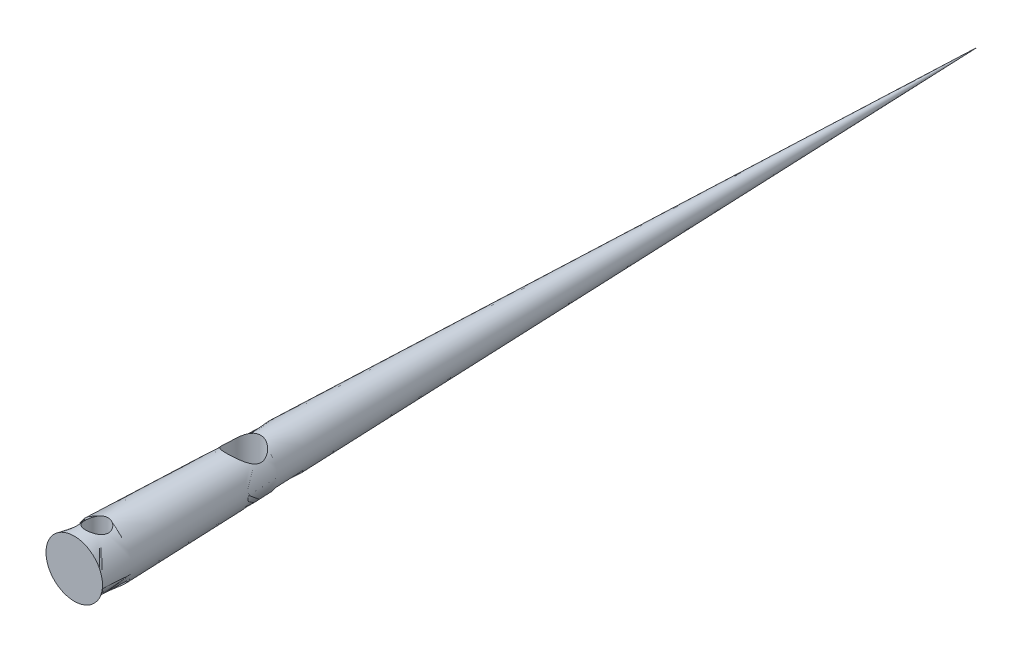
from build123d import *

# Parameters (mm, degrees)
SKETCH4_R               = 1.5
CUT_EXTRUDE3_DEPTH      = 3.5
CUT_EXTRUDE3_DEPTH_BACK = 3.5
SKETCH7_R               = 1
CUT_EXTRUDE4_DEPTH      = 3.5000001
CUT_EXTRUDE4_DEPTH_BACK = 3.5000001


with BuildPart() as part:
    # Sketch2 → Revolve2 (revolve)
    with BuildSketch(Plane(origin=(0, 0, 0), x_dir=(1, 0, 0), z_dir=(0, 1, 0))):
        Polygon((0, 0), (2.5, 0), (0, 80), align=None)
    revolve(axis=Axis((0, 0, -80), (0, 0, 1)))

    # Sketch4 → Cut-Extrude3 (cut, two sides)
    with BuildSketch(Plane(origin=(0, 0, 0), x_dir=(1, 0, 0), z_dir=(0, 1, 0))) as cut_extrude3_sk:
        with Locations((0, 15)):
            Circle(SKETCH4_R)
    extrude(amount=CUT_EXTRUDE3_DEPTH, mode=Mode.SUBTRACT)
    extrude(cut_extrude3_sk.sketch, amount=-CUT_EXTRUDE3_DEPTH_BACK, mode=Mode.SUBTRACT)

    # Sketch7 → Cut-Extrude4 (cut, two sides)
    with BuildSketch(Plane(origin=(0, 0, 0), x_dir=(1, 0, 0), z_dir=(0, 1, 0))) as cut_extrude4_sk:
        with Locations((0, 2)):
            Circle(SKETCH7_R)
    extrude(amount=CUT_EXTRUDE4_DEPTH, mode=Mode.SUBTRACT)
    extrude(cut_extrude4_sk.sketch, amount=-CUT_EXTRUDE4_DEPTH_BACK, mode=Mode.SUBTRACT)


solid = part.part
